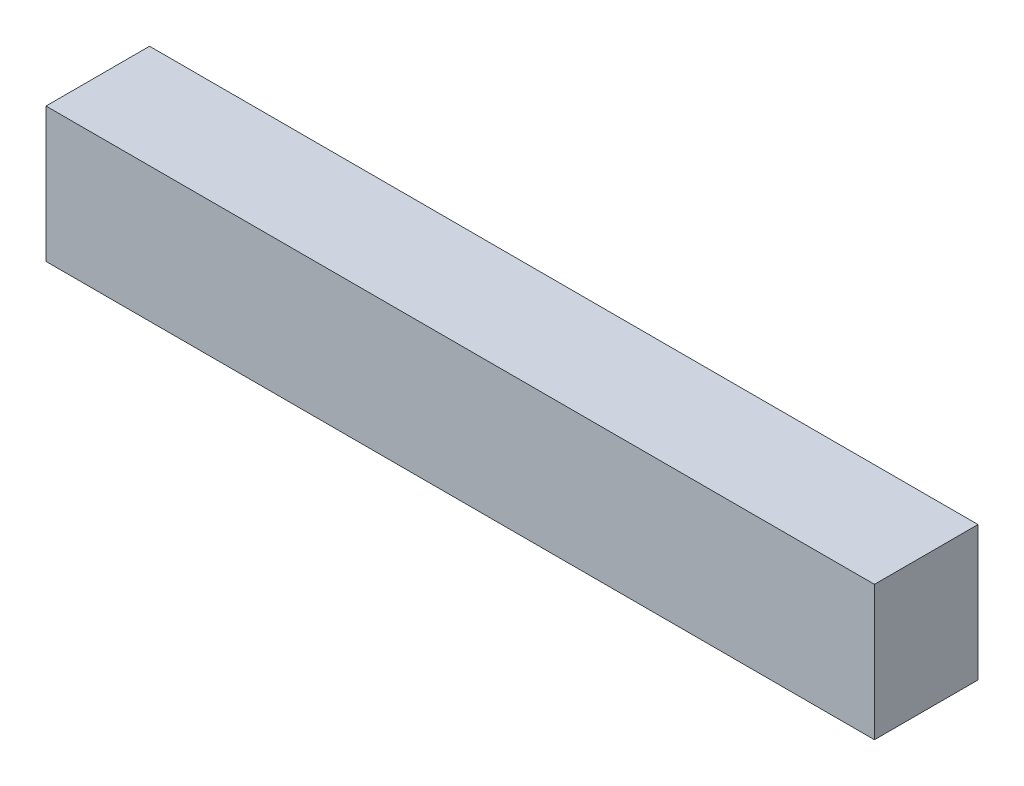
from build123d import *

# Parameters (mm, degrees)
SKETCH2_W           = 40
SKETCH2_H           = 6.5
BOSS_EXTRUDE1_DEPTH = 5


with BuildPart() as part:
    # Sketch2 → Boss-Extrude1 (new body)
    with BuildSketch(Plane.XY):
        Rectangle(SKETCH2_W, SKETCH2_H)
    extrude(amount=BOSS_EXTRUDE1_DEPTH)


solid = part.part
